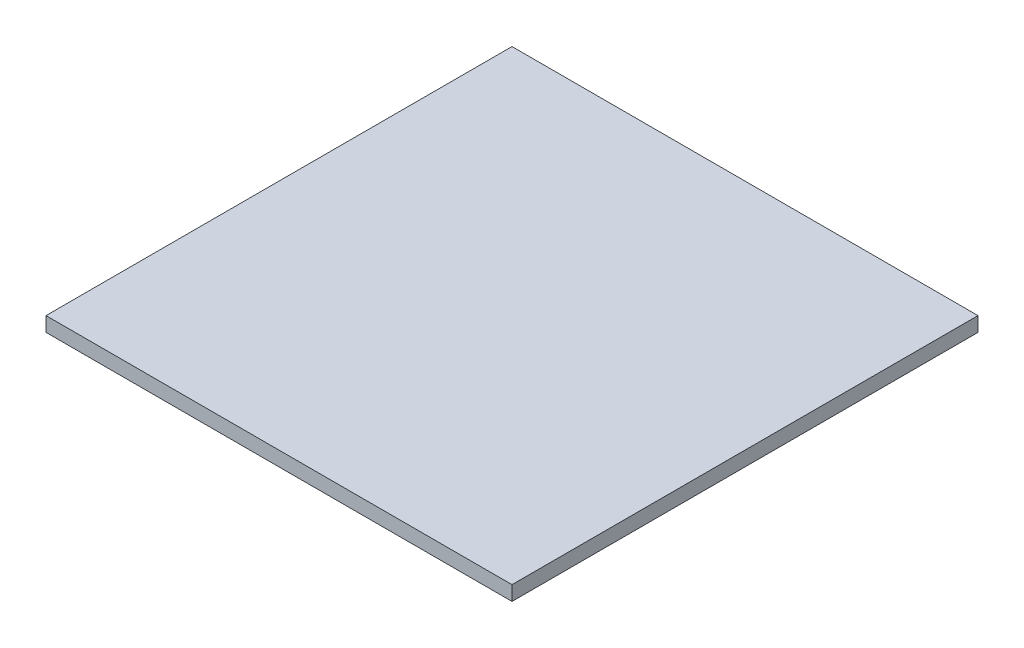
from build123d import *

# Parameters (mm, degrees)
SKETCH2_W           = 64
SKETCH2_H           = 64
BOSS_EXTRUDE1_DEPTH = 2


with BuildPart() as part:
    # Sketch2 → Boss-Extrude1 (new body)
    with BuildSketch(Plane(origin=(0, 0, 0), x_dir=(1, 0, 0), z_dir=(0, 1, 0))):
        with Locations((-32, -32)):
            Rectangle(SKETCH2_W, SKETCH2_H)
    extrude(amount=BOSS_EXTRUDE1_DEPTH)


solid = part.part
